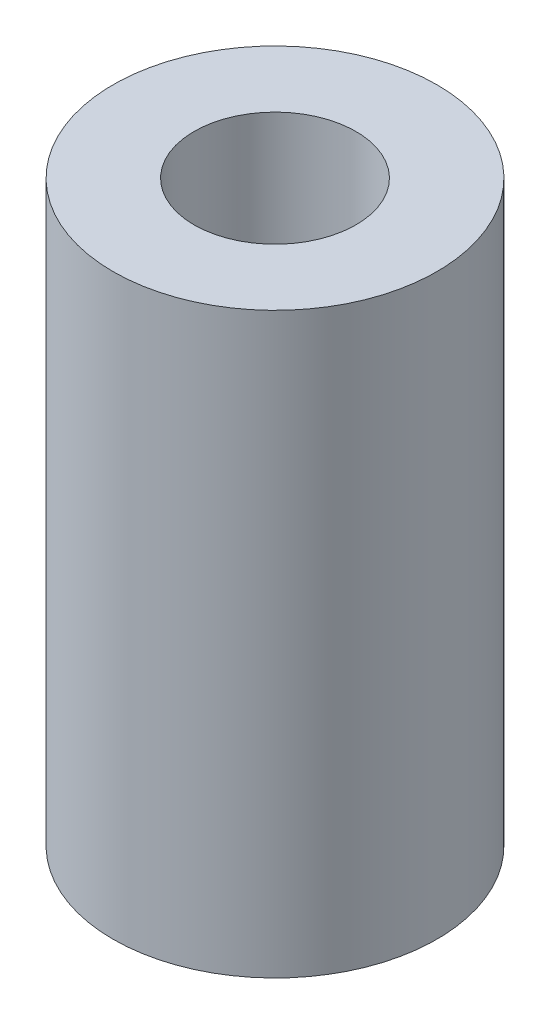
from build123d import *

# Parameters (mm, degrees)
CROQUIS1_R              = 7
CROQUIS1_R_2            = 3.5
SALIENTE_EXTRUIR1_DEPTH = 25


with BuildPart() as part:
    # Croquis1 → Saliente-Extruir1 (new body)
    with BuildSketch(Plane(origin=(0, 0, 0), x_dir=(1, 0, 0), z_dir=(0, 1, 0))):
        Circle(CROQUIS1_R)
        Circle(CROQUIS1_R_2, mode=Mode.SUBTRACT)
    extrude(amount=SALIENTE_EXTRUIR1_DEPTH)


solid = part.part
